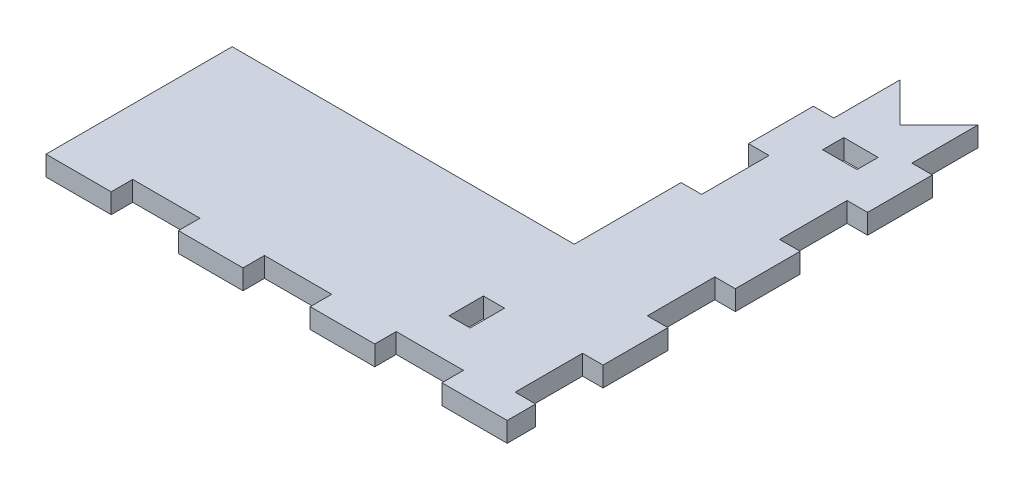
from build123d import *

# Parameters (mm, degrees)
BOSS_EXTRUDE1_DEPTH = 3
SKETCH8_W           = 3.2
SKETCH8_H           = 10.2
SKETCH8_W_2         = 5.2
SKETCH8_H_2         = 3.2
SKETCH8_H_3         = 5.2
CUT_EXTRUDE4_DEPTH  = 4
CUT_EXTRUDE2_DEPTH  = 4


with BuildPart() as part:
    # Sketch1 → Boss-Extrude1 (new body)
    with BuildSketch(Plane(origin=(0, 0, 0), x_dir=(1, 0, 0), z_dir=(0, 1, 0))):
        Polygon((-34.872217102, 0), (34.872217102, 0), (34.872217102, 75), (16.872217102, 75), (16.872217102, 28.75), (-34.872217102, 28.75), align=None)
    extrude(amount=-BOSS_EXTRUDE1_DEPTH)

    # Sketch8 → Cut-Extrude4 (cut, through all)
    with BuildSketch(Plane(origin=(0, 0, 0), x_dir=(1, 0, 0), z_dir=(0, 1, 0))):
        with Locations((33.372217102, 50)):
            Rectangle(SKETCH8_W, SKETCH8_H)
        with Locations((33.372217102, 70)):
            Rectangle(SKETCH8_W, SKETCH8_H)
        with Locations((25.872217102, 61.5)):
            Rectangle(SKETCH8_W_2, SKETCH8_H_2)
        with Locations((33.372217102, 10)):
            Rectangle(SKETCH8_W, SKETCH8_H)
        with Locations((33.372217102, 30)):
            Rectangle(SKETCH8_W, SKETCH8_H)
        with Locations((18.372217102, 12.5)):
            Rectangle(SKETCH8_W, SKETCH8_H_3)
        with Locations((18.372217102, 70)):
            Rectangle(SKETCH8_W, SKETCH8_H)
        Polygon((-34.972217102, 0.6), (-34.972217102, -0.1), (34.972217102, -0.1), (34.972217102, 0.6), (25.008726501, 0.6), (25.008726501, 3.85), (14.845235901, 3.85), (14.845235901, 0.6), (5.0817453, 0.6), (5.0817453, 3.85), (-5.0817453, 3.85), (-5.0817453, 0.6), (-14.845235901, 0.6), (-14.845235901, 3.85), (-25.008726501, 3.85), (-25.008726501, 0.6), align=None)
        with Locations((18.372217102, 50)):
            Rectangle(SKETCH8_W, SKETCH8_H)
    extrude(amount=-CUT_EXTRUDE4_DEPTH, mode=Mode.SUBTRACT)

    # Sketch5 → Cut-Extrude2 (cut, through all)
    with BuildSketch(Plane(origin=(0, 0, 0), x_dir=(1, 0, 0), z_dir=(0, 1, 0))):
        Polygon((31.872217102, 75), (25.872217102, 69), (19.872217102, 75), align=None)
    extrude(amount=-CUT_EXTRUDE2_DEPTH, mode=Mode.SUBTRACT)


solid = part.part
